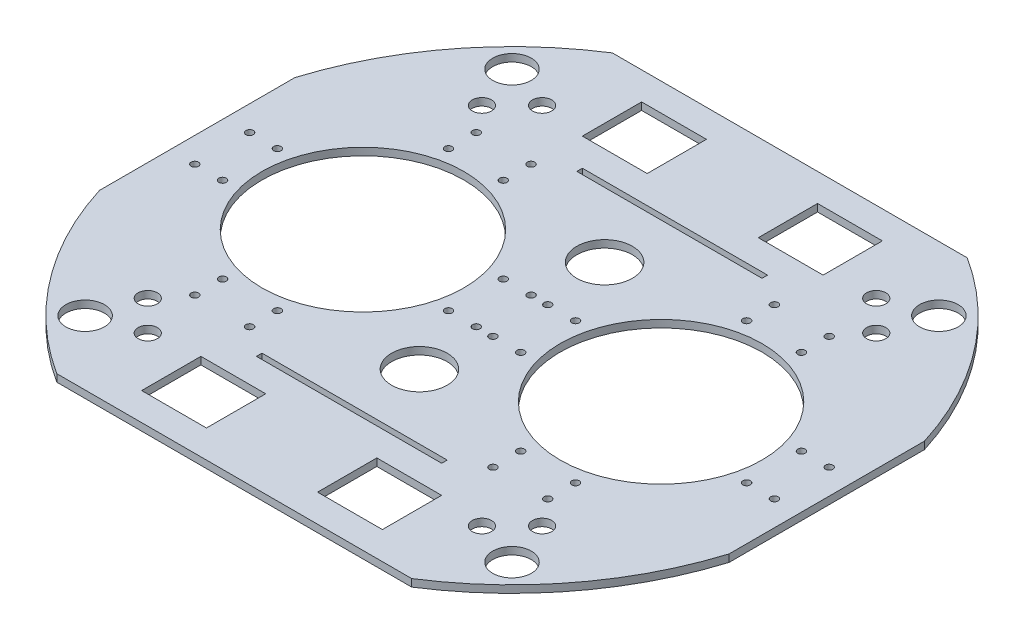
from build123d import *

# Parameters (mm, degrees)
SKETCH_1_R          = 178
EXTRUDE_1_DEPTH     = 4
SKETCH_2_R          = 10.414
SKETCH_2_R_2        = 5.2
CUT_EXTRUDE_1_DEPTH = 10
SKETCH_4_R          = 54.5
CUT_EXTRUDE_2_DEPTH = 10
SKETCH_5_R          = 2
CUT_EXTRUDE_3_DEPTH = 10
CUT_EXTRUDE_4_DEPTH = 10
SKETCH_11_W         = 100
SKETCH_11_H         = 3
CUT_EXTRUDE_5_DEPTH = 10
SKETCH_13_R         = 15
CUT_EXTRUDE_6_DEPTH = 10


with BuildPart() as part:
    # 草图1 → 凸台-拉伸1 (new body)
    with BuildSketch(Plane(origin=(0, 0, 0), x_dir=(1, 0, 0), z_dir=(0, 1, 0))):
        Circle(SKETCH_1_R)
    extrude(amount=EXTRUDE_1_DEPTH)

    # 草图2 → 切除-拉伸1 (cut)
    with BuildSketch(Plane(origin=(0, 4, 0), x_dir=(1, 0, 0), z_dir=(0, 1, 0))):
        with Locations((115.258405333, 115.258405333)):
            Circle(SKETCH_2_R)
        with Locations((-90.216925784, -106.480381752)):
            Circle(SKETCH_2_R_2)
        with Locations((-106.480381752, -90.216925784)):
            Circle(SKETCH_2_R_2)
        with Locations((115.258405333, -115.258405333)):
            Circle(SKETCH_2_R)
        with Locations((-115.258405333, -115.258405333)):
            Circle(SKETCH_2_R)
        with Locations((-115.258405333, 115.258405333)):
            Circle(SKETCH_2_R)
        with Locations((-90.216925784, 106.480381752)):
            Circle(SKETCH_2_R_2)
        with Locations((-106.480381752, 90.216925784)):
            Circle(SKETCH_2_R_2)
        with Locations((106.480381752, 90.216925784)):
            Circle(SKETCH_2_R_2)
        with Locations((90.216925784, 106.480381752)):
            Circle(SKETCH_2_R_2)
        with Locations((90.216925784, -106.480381752)):
            Circle(SKETCH_2_R_2)
        with Locations((106.480381752, -90.216925784)):
            Circle(SKETCH_2_R_2)
    extrude(amount=-CUT_EXTRUDE_1_DEPTH, mode=Mode.SUBTRACT)

    # 草图4 → 切除-拉伸2 (cut)
    with BuildSketch(Plane.XZ):
        with Locations((80.5, 0)):
            Circle(SKETCH_4_R)
        with Locations((-80.5, 0)):
            Circle(SKETCH_4_R)
    extrude(amount=-CUT_EXTRUDE_2_DEPTH, mode=Mode.SUBTRACT)

    # 草图5 → 切除-拉伸3 (cut)
    with BuildSketch(Plane(origin=(0, 4, 0), x_dir=(1, 0, 0), z_dir=(0, 1, 0))):
        with Locations((-19.5, -14.8)):
            Circle(SKETCH_5_R)
        with Locations((-4.5, -14.8)):
            Circle(SKETCH_5_R)
        with Locations((-4.5, 14.8)):
            Circle(SKETCH_5_R)
        with Locations((-19.5, 14.8)):
            Circle(SKETCH_5_R)
        with Locations((4.5, -14.8)):
            Circle(SKETCH_5_R)
        with Locations((19.5, -14.8)):
            Circle(SKETCH_5_R)
        with Locations((19.5, 14.8)):
            Circle(SKETCH_5_R)
        with Locations((4.5, 14.8)):
            Circle(SKETCH_5_R)
        with Locations((-65.7, -61)):
            Circle(SKETCH_5_R)
        with Locations((-65.7, -76)):
            Circle(SKETCH_5_R)
        with Locations((-95.3, -61)):
            Circle(SKETCH_5_R)
        with Locations((-95.3, -76)):
            Circle(SKETCH_5_R)
        with Locations((-141.5, -14.8)):
            Circle(SKETCH_5_R)
        with Locations((-156.5, -14.8)):
            Circle(SKETCH_5_R)
        with Locations((-141.5, 14.8)):
            Circle(SKETCH_5_R)
        with Locations((-156.5, 14.8)):
            Circle(SKETCH_5_R)
        with Locations((-95.3, 61)):
            Circle(SKETCH_5_R)
        with Locations((-95.3, 76)):
            Circle(SKETCH_5_R)
        with Locations((-65.7, 61)):
            Circle(SKETCH_5_R)
        with Locations((-65.7, 76)):
            Circle(SKETCH_5_R)
        with Locations((95.3, 76)):
            Circle(SKETCH_5_R)
        with Locations((95.3, 61)):
            Circle(SKETCH_5_R)
        with Locations((65.7, 76)):
            Circle(SKETCH_5_R)
        with Locations((65.7, 61)):
            Circle(SKETCH_5_R)
        with Locations((156.5, -14.8)):
            Circle(SKETCH_5_R)
        with Locations((141.5, -14.8)):
            Circle(SKETCH_5_R)
        with Locations((156.5, 14.8)):
            Circle(SKETCH_5_R)
        with Locations((141.5, 14.8)):
            Circle(SKETCH_5_R)
        with Locations((65.7, -76)):
            Circle(SKETCH_5_R)
        with Locations((65.7, -61)):
            Circle(SKETCH_5_R)
        with Locations((95.3, -76)):
            Circle(SKETCH_5_R)
        with Locations((95.3, -61)):
            Circle(SKETCH_5_R)
    extrude(amount=-CUT_EXTRUDE_3_DEPTH, mode=Mode.SUBTRACT)

    # 草图8 → 切除-拉伸4 (cut)
    with BuildSketch(Plane.XZ):
        with BuildLine():
            Line((95.833188406, 150), (0, 150))
            Line((0, 150), (-95.833188406, 150))
            ThreePointArc((-95.833188406, 150), (0, 178), (95.833188406, 150))
        make_face()
        with BuildLine():
            Line((170, 52.763623833), (170, 0))
            Line((170, 0), (170, -52.763623833))
            ThreePointArc((170, -52.763623833), (178, 0), (170, 52.763623833))
        make_face()
        with BuildLine():
            Line((0, -150), (-95.833188406, -150))
            ThreePointArc((-95.833188406, -150), (0, -178), (95.833188406, -150))
            Line((95.833188406, -150), (0, -150))
        make_face()
        with BuildLine():
            Line((-170, 0), (-170, -52.763623833))
            ThreePointArc((-170, -52.763623833), (-178, 0), (-170, 52.763623833))
            Line((-170, 52.763623833), (-170, 0))
        make_face()
    extrude(amount=-CUT_EXTRUDE_4_DEPTH, mode=Mode.SUBTRACT)

    # 草图11 → 切除-拉伸5 (cut)
    with BuildSketch(Plane.XZ):
        with Locations((0, -86.5)):
            Rectangle(SKETCH_11_W, SKETCH_11_H)
        Polygon((65, -135), (30, -135), (30, -119), (30, -103), (65, -103), align=None)
        Polygon((-65, -119), (-65, -103), (-30, -103), (-30, -119), (-30, -135), (-65, -135), align=None)
        with Locations((0, 86.5)):
            Rectangle(SKETCH_11_W, SKETCH_11_H)
        Polygon((-65, 119), (-65, 103), (-30, 103), (-30, 119), (-30, 135), (-65, 135), align=None)
        Polygon((65, 103), (65, 135), (30, 135), (30, 119), (30, 103), align=None)
    extrude(amount=-CUT_EXTRUDE_5_DEPTH, mode=Mode.SUBTRACT)

    # 草图13 → 切除-拉伸6 (cut)
    with BuildSketch(Plane.XZ):
        with Locations((0, -50)):
            Circle(SKETCH_13_R)
        with Locations((0, 50)):
            Circle(SKETCH_13_R)
    extrude(amount=-CUT_EXTRUDE_6_DEPTH, mode=Mode.SUBTRACT)


solid = part.part
